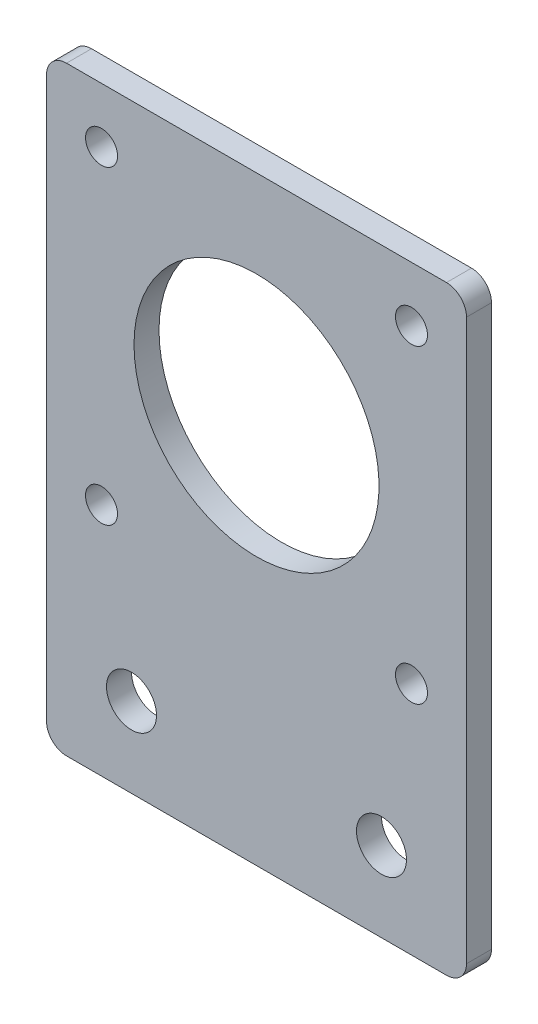
from build123d import *

# Parameters (mm, degrees)
SKETCH1_R           = 2.5
SKETCH1_R_2         = 1.6
SKETCH1_R_3         = 12.25
BOSS_EXTRUDE1_DEPTH = 2.5


with BuildPart() as part:
    # Sketch1 → Boss-Extrude1 (new body)
    with BuildSketch(Plane.XY.offset(1.25)):
        with BuildLine():
            Line((-21, 19), (-21, -37))
            ThreePointArc((-21, -37), (-20.414213562, -38.414213562), (-19, -39))
            Line((-19, -39), (19, -39))
            ThreePointArc((19, -39), (20.414213562, -38.414213562), (21, -37))
            Line((21, -37), (21, 19))
            ThreePointArc((21, 19), (20.414213562, 20.414213562), (19, 21))
            Line((19, 21), (-19, 21))
            ThreePointArc((-19, 21), (-20.414213562, 20.414213562), (-21, 19))
        make_face()
        with Locations((-12.5, -31)):
            Circle(SKETCH1_R, mode=Mode.SUBTRACT)
        with Locations((-15.5, 15.5)):
            Circle(SKETCH1_R_2, mode=Mode.SUBTRACT)
        with Locations((15.5, -15.5)):
            Circle(SKETCH1_R_2, mode=Mode.SUBTRACT)
        Circle(SKETCH1_R_3, mode=Mode.SUBTRACT)
        with Locations((-15.5, -15.5)):
            Circle(SKETCH1_R_2, mode=Mode.SUBTRACT)
        with Locations((15.5, 15.5)):
            Circle(SKETCH1_R_2, mode=Mode.SUBTRACT)
        with Locations((12.5, -31)):
            Circle(SKETCH1_R, mode=Mode.SUBTRACT)
    extrude(amount=-BOSS_EXTRUDE1_DEPTH)


solid = part.part
